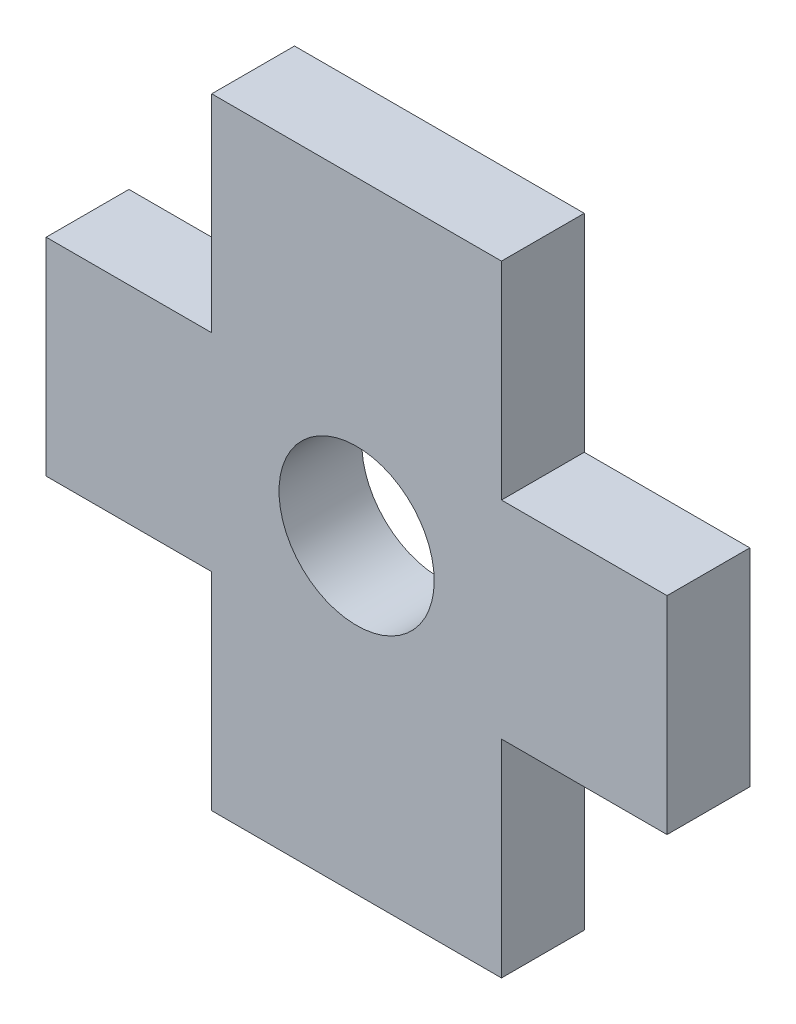
from build123d import *

# Parameters (mm, degrees)
SKETCH1_R           = 1.5
BOSS_EXTRUDE1_DEPTH = 1.6


with BuildPart() as part:
    # Sketch1 → Boss-Extrude1 (new body)
    with BuildSketch(Plane.XY):
        Polygon((-2.8, -6), (2.8, -6), (2.8, -2), (6, -2), (6, 2), (2.8, 2), (2.8, 6), (-2.8, 6), (-2.8, 2), (-6, 2), (-6, -2), (-2.8, -2), align=None)
        Circle(SKETCH1_R, mode=Mode.SUBTRACT)
    extrude(amount=BOSS_EXTRUDE1_DEPTH)


solid = part.part
